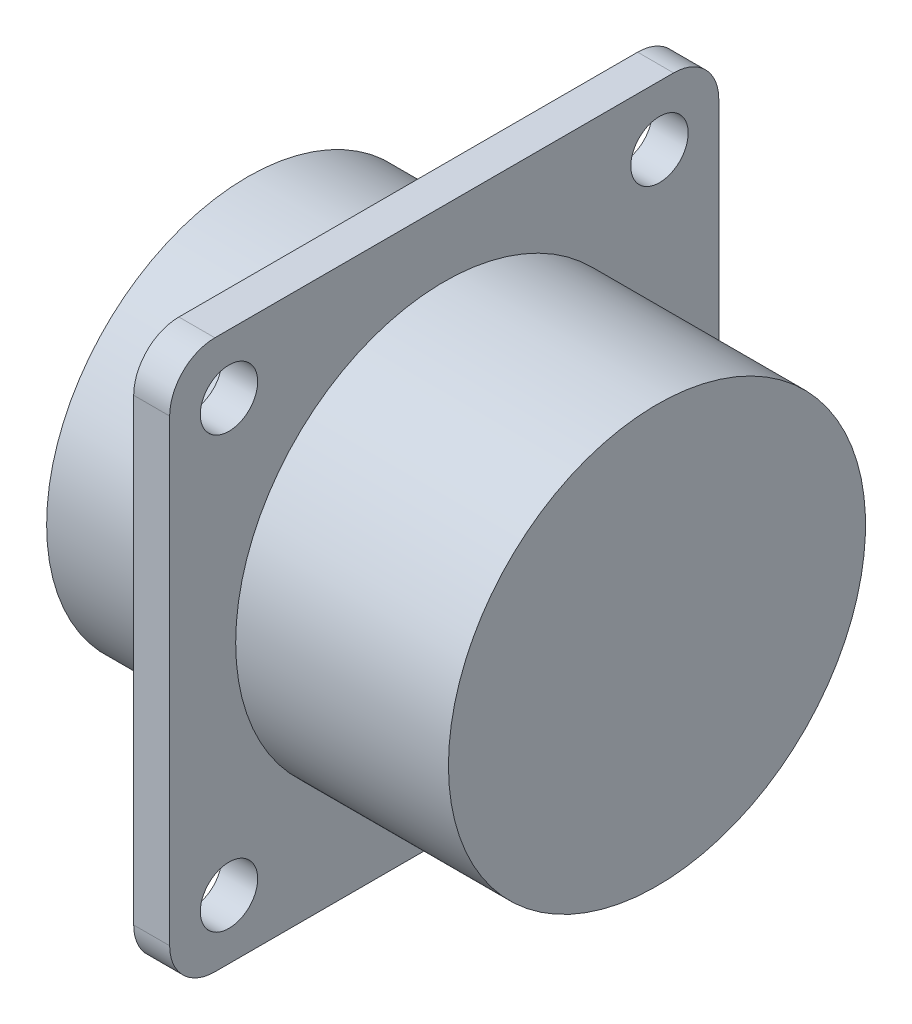
from build123d import *

# Parameters (mm, degrees)
SKETCH2_OUTSIDE_W  = 79.82
SKETCH2_OUTSIDE_H  = 79.82
SKETCH2_OUTSIDE_R  = 1.905
CUT_EXTRUDE1_DEPTH = 17.51


with BuildPart() as part:
    # Sketch1 → Revolve1 (revolve)
    with BuildSketch(Plane.XY, mode=Mode.PRIVATE) as revolve1_sk:
        Polygon((0, 0), (0, 13.335), (10.668, 13.335), (10.668, 30), (13.0556, 30), (13.0556, 13.843), (27.178, 13.843), (27.178, 0), align=None)
    revolve(revolve1_sk.sketch.rotate(Axis((0, 0, 0), (1, 0, 0)), 90), axis=Axis((0, 0, 0), (1, 0, 0)))  # turned: the seam where the file's is

    # Sketch2 outside → Cut-Extrude1 (cut, through all)
    with BuildSketch(Plane.ZY.offset(-10.668)):
        Rectangle(SKETCH2_OUTSIDE_W, SKETCH2_OUTSIDE_H)
        with BuildLine():
            Line((-15.2245, 18.2245), (15.2245, 18.2245))
            ThreePointArc((15.2245, 18.2245), (17.345820344, 17.345820344), (18.2245, 15.2245))
            Line((18.2245, 15.2245), (18.2245, -15.2245))
            ThreePointArc((18.2245, -15.2245), (17.345820344, -17.345820344), (15.2245, -18.2245))
            Line((15.2245, -18.2245), (-15.2245, -18.2245))
            ThreePointArc((-15.2245, -18.2245), (-17.345820344, -17.345820344), (-18.2245, -15.2245))
            Line((-18.2245, -15.2245), (-18.2245, 15.2245))
            ThreePointArc((-18.2245, 15.2245), (-17.345820344, 17.345820344), (-15.2245, 18.2245))
        make_face(mode=Mode.SUBTRACT)
        with Locations((14.2875, 14.2875)):
            Circle(SKETCH2_OUTSIDE_R)
        with Locations((-14.2875, 14.2875)):
            Circle(SKETCH2_OUTSIDE_R)
        with Locations((-14.2875, -14.2875)):
            Circle(SKETCH2_OUTSIDE_R)
        with Locations((14.2875, -14.2875)):
            Circle(SKETCH2_OUTSIDE_R)
    extrude(amount=-CUT_EXTRUDE1_DEPTH, mode=Mode.SUBTRACT)


solid = part.part
